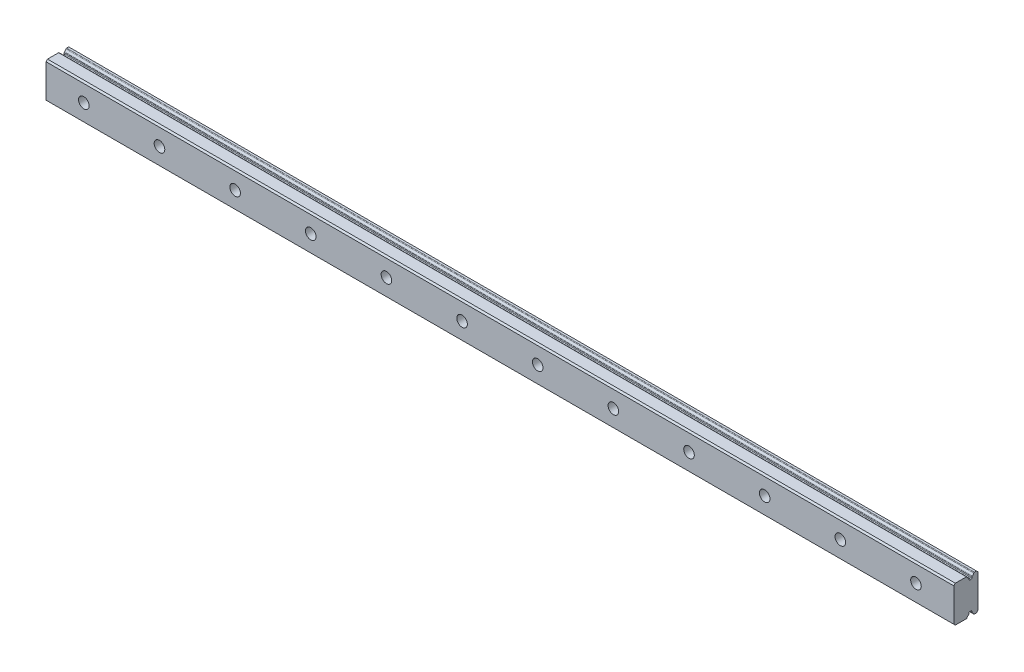
from build123d import *

# Parameters (mm, degrees)
BOSS_EXTRU_1_DEPTH                                 = 300
CHAMBRAGE_POUR_VIS_T_TE_HEXAGONALE_M31_D           = 3.5
CHAMBRAGE_POUR_VIS_T_TE_HEXAGONALE_M31_DEPTH       = 8.000000001
CHAMBRAGE_POUR_VIS_T_TE_HEXAGONALE_M31_CBORE_D     = 6
CHAMBRAGE_POUR_VIS_T_TE_HEXAGONALE_M31_CBORE_DEPTH = 4.500000001


with BuildPart() as part:
    # Esquisse1 → Boss.-Extru.1 (new body)
    with BuildSketch(Plane(origin=(-167.5, 0, 0), x_dir=(0, -1, 0), z_dir=(-1, 0, 0))):
        with BuildLine():
            Line((-157, 193.75), (-168, 193.75))
            Line((-168, 193.75), (-168.5, 193.25))
            Line((-168.5, 193.25), (-168.5, 189.607879579))
            ThreePointArc((-168.5, 189.607879579), (-168.4576137, 189.468608075), (-168.344827586, 189.376562202))
            ThreePointArc((-168.344827586, 189.376562202), (-168.01524529, 189.174071401), (-167.767205011, 188.877249849))
            ThreePointArc((-167.767205011, 188.877249849), (-167.685241932, 188.792985122), (-167.573828324, 188.755495145))
            Line((-167.573828324, 188.755495145), (-167.228211064, 188.725257552))
            ThreePointArc((-167.228211064, 188.725257552), (-167.065680666, 188.64510643), (-167, 188.476208878))
            Line((-167, 188.476208878), (-167, 188.023787121))
            ThreePointArc((-167, 188.023787121), (-167.065680666, 187.854889569), (-167.228211064, 187.774738446))
            Line((-167.228211064, 187.774738446), (-167.59477657, 187.74266812))
            ThreePointArc((-167.59477657, 187.74266812), (-167.703244499, 187.707004425), (-167.784541491, 187.626829678))
            ThreePointArc((-167.784541491, 187.626829678), (-168.027906161, 187.347614221), (-168.344827586, 187.155915383))
            ThreePointArc((-168.344827586, 187.155915383), (-168.4576137, 187.06386951), (-168.5, 186.924598006))
            Line((-168.5, 186.924598006), (-168.5, 186.249999999))
            Line((-168.5, 186.249999999), (-168, 185.749999999))
            Line((-168, 185.749999999), (-157, 185.749999999))
            Line((-157, 185.749999999), (-156.5, 186.249999999))
            Line((-156.5, 186.249999999), (-156.5, 186.924598006))
            ThreePointArc((-156.5, 186.924598006), (-156.5423863, 187.06386951), (-156.655172414, 187.155915383))
            ThreePointArc((-156.655172414, 187.155915383), (-156.972093839, 187.347614221), (-157.215458509, 187.626829678))
            ThreePointArc((-157.215458509, 187.626829678), (-157.296755501, 187.707004425), (-157.40522343, 187.74266812))
            Line((-157.40522343, 187.74266812), (-157.771788936, 187.774738446))
            ThreePointArc((-157.771788936, 187.774738446), (-157.934319334, 187.854889569), (-158, 188.023787121))
            Line((-158, 188.023787121), (-158, 188.476208878))
            ThreePointArc((-158, 188.476208878), (-157.934319334, 188.64510643), (-157.771788936, 188.725257552))
            Line((-157.771788936, 188.725257552), (-157.426171676, 188.755495145))
            ThreePointArc((-157.426171676, 188.755495145), (-157.314758068, 188.792985122), (-157.232794989, 188.877249849))
            ThreePointArc((-157.232794989, 188.877249849), (-156.98475471, 189.174071401), (-156.655172414, 189.376562202))
            ThreePointArc((-156.655172414, 189.376562202), (-156.5423863, 189.468608075), (-156.5, 189.607879579))
            Line((-156.5, 189.607879579), (-156.5, 193.25))
            Line((-156.5, 193.25), (-157, 193.75))
        make_face()
    extrude(amount=-BOSS_EXTRU_1_DEPTH)

    # Chambrage pour vis à tête hexagonale M31
    with Locations(Plane(origin=(0, 0, 185.749999999), x_dir=(-1, 0, 0), z_dir=(0, 0, -1))):
        with Locations((155, 162.5), (130, 162.5), (105, 162.5), (80, 162.5), (55, 162.5), (30, 162.5), (5, 162.5), (-20, 162.5), (-45, 162.5), (-70, 162.5), (-95, 162.5), (-120, 162.5), (-147.5, 162.5)):
            CounterBoreHole(CHAMBRAGE_POUR_VIS_T_TE_HEXAGONALE_M31_D / 2, CHAMBRAGE_POUR_VIS_T_TE_HEXAGONALE_M31_CBORE_D / 2, CHAMBRAGE_POUR_VIS_T_TE_HEXAGONALE_M31_CBORE_DEPTH, depth=CHAMBRAGE_POUR_VIS_T_TE_HEXAGONALE_M31_DEPTH)


solid = part.part
